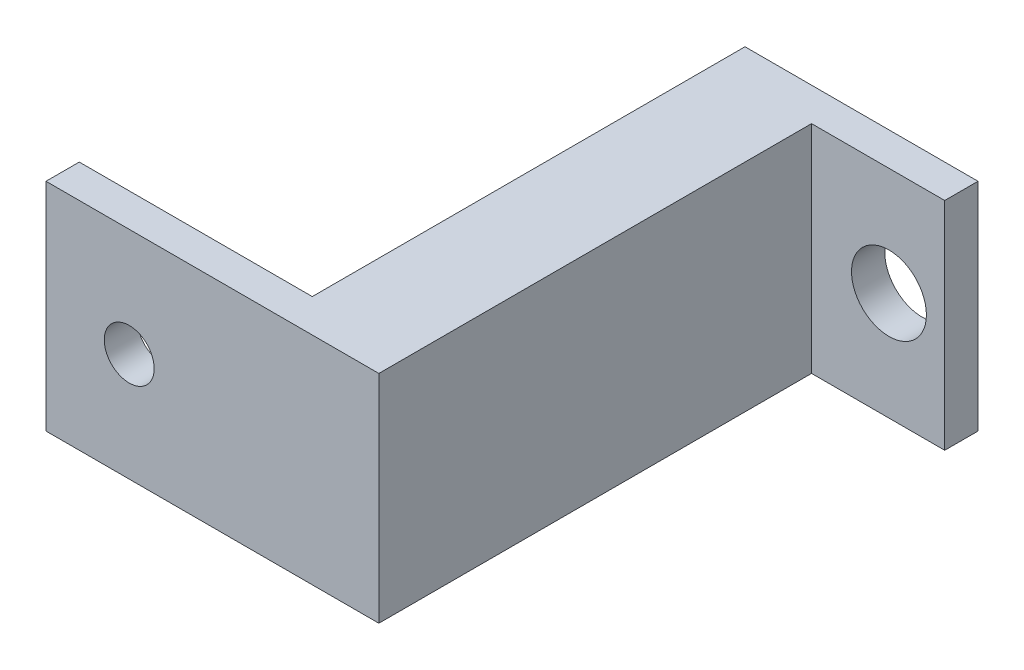
from build123d import *

# Parameters (mm, degrees)
SZKIC1_W                    = 14
SZKIC1_H                    = 13
SZKIC1_R                    = 2.25
DODANIE_WYCI_GNI_CIE1_DEPTH = 2
SZKIC2_W                    = 6
SZKIC2_H                    = 13
DODANIE_WYCI_GNI_CIE2_DEPTH = 24
SZKIC3_W                    = 20
SZKIC3_H                    = 13
SZKIC3_R                    = 1.5
DODANIE_WYCI_GNI_CIE3_DEPTH = 2


with BuildPart() as part:
    # Szkic1 → Dodanie-wyciągnięcie1 (new body)
    with BuildSketch(Plane.XY):
        Rectangle(SZKIC1_W, SZKIC1_H)
        with Locations((3.65, 0)):
            Circle(SZKIC1_R, mode=Mode.SUBTRACT)
    extrude(amount=DODANIE_WYCI_GNI_CIE1_DEPTH)

    # Szkic2 → Dodanie-wyciągnięcie2 (add)
    with BuildSketch(Plane.XY.offset(2)):
        with Locations((-4, 0)):
            Rectangle(SZKIC2_W, SZKIC2_H)
    extrude(amount=DODANIE_WYCI_GNI_CIE2_DEPTH)

    # Szkic3 → Dodanie-wyciągnięcie3 (add)
    with BuildSketch(Plane.XY.offset(26)):
        with Locations((-11, 0)):
            Rectangle(SZKIC3_W, SZKIC3_H)
        with Locations((-16, 0)):
            Circle(SZKIC3_R, mode=Mode.SUBTRACT)
    extrude(amount=DODANIE_WYCI_GNI_CIE3_DEPTH)


solid = part.part
